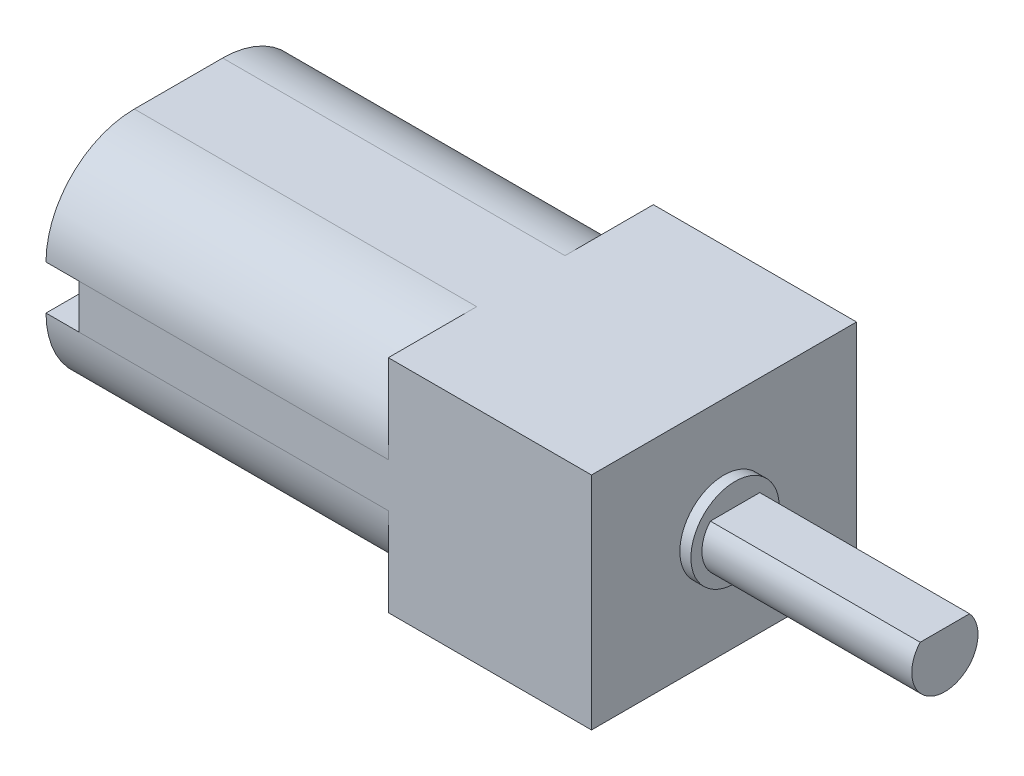
from build123d import *

# Parameters (mm, degrees)
SKETCH1_W           = 9.2
SKETCH1_H           = 12
BOSS_EXTRUDE1_DEPTH = 5
SKETCH3_R           = 2
BOSS_EXTRUDE2_DEPTH = 0.5
SKETCH4_R           = 1.5
BOSS_EXTRUDE3_DEPTH = 9.5
CUT_EXTRUDE1_DEPTH  = 9.5
BOSS_EXTRUDE4_DEPTH = 15.5
SKETCH8_W           = 1.5
SKETCH8_H           = 2
CUT_EXTRUDE2_DEPTH  = 1.5
SKETCH9_W           = 0.4
SKETCH9_H           = 1.196619736
BOSS_EXTRUDE5_DEPTH = 1.7
SKETCH10_R          = 2.5
BOSS_EXTRUDE6_DEPTH = 1.5
SKETCH11_R          = 1.675952799
CUT_EXTRUDE3_DEPTH  = 0.5


with BuildPart() as part:
    # Sketch1 → Boss-Extrude1 (new body, symmetric)
    with BuildSketch(Plane(origin=(0, 0, 0), x_dir=(1, 0, 0), z_dir=(0, 1, 0))):
        Rectangle(SKETCH1_W, SKETCH1_H)
    extrude(amount=BOSS_EXTRUDE1_DEPTH, both=True)

    # Sketch3 → Boss-Extrude2 (add)
    with BuildSketch(Plane(origin=(4.6, 0, 0), x_dir=(0, 0, -1), z_dir=(1, 0, 0))):
        Circle(SKETCH3_R)
    extrude(amount=BOSS_EXTRUDE2_DEPTH)

    # Sketch4 → Boss-Extrude3 (add)
    with BuildSketch(Plane(origin=(5.1, 0, 0), x_dir=(0, 0, -1), z_dir=(1, 0, 0))):
        Circle(SKETCH4_R)
    extrude(amount=BOSS_EXTRUDE3_DEPTH)

    # Sketch5 → Cut-Extrude1 (cut)
    with BuildSketch(Plane(origin=(14.6, 0, 0), x_dir=(0, 0, -1), z_dir=(1, 0, 0))):
        with BuildLine():
            Line((-1.118033989, 1), (1.118033989, 1))
            ThreePointArc((1.118033989, 1), (0, 1.5), (-1.118033989, 1))
        make_face()
    extrude(amount=-CUT_EXTRUDE1_DEPTH, mode=Mode.SUBTRACT)

    # Sketch7 → Boss-Extrude4 (add)
    with BuildSketch(Plane.ZY.offset(4.6)):
        with BuildLine():
            Line((-2, -5), (2, -5))
            ThreePointArc((2, -5), (4.828427125, -3.828427125), (6, -1))
            Line((6, -1), (6, 1))
            ThreePointArc((6, 1), (4.828427125, 3.828427125), (2, 5))
            Line((2, 5), (-2, 5))
            ThreePointArc((-2, 5), (-4.828427125, 3.828427125), (-6, 1))
            Line((-6, 1), (-6, -1))
            ThreePointArc((-6, -1), (-4.828427125, -3.828427125), (-2, -5))
        make_face()
    extrude(amount=BOSS_EXTRUDE4_DEPTH)

    # Sketch8 → Cut-Extrude2 (cut)
    with BuildSketch(Plane.ZY.offset(20.1)):
        with Locations((-5.25, 0)):
            Rectangle(SKETCH8_W, SKETCH8_H)
        with Locations((5.25, 0)):
            Rectangle(SKETCH8_W, SKETCH8_H)
    extrude(amount=-CUT_EXTRUDE2_DEPTH, mode=Mode.SUBTRACT)

    # Sketch9 → Boss-Extrude5 (add)
    with BuildSketch(Plane.ZY.offset(20.1)):
        with Locations((-3.5, 0)):
            Rectangle(SKETCH9_W, SKETCH9_H)
        with Locations((3.5, 0)):
            Rectangle(SKETCH9_W, SKETCH9_H)
    extrude(amount=BOSS_EXTRUDE5_DEPTH)

    # Sketch10 → Boss-Extrude6 (add)
    with BuildSketch(Plane.ZY.offset(20.1)):
        Circle(SKETCH10_R)
    extrude(amount=BOSS_EXTRUDE6_DEPTH)

    # Sketch11 → Cut-Extrude3 (cut)
    with BuildSketch(Plane.ZY.offset(21.6)):
        Circle(SKETCH11_R)
    extrude(amount=-CUT_EXTRUDE3_DEPTH, mode=Mode.SUBTRACT)


solid = part.part
